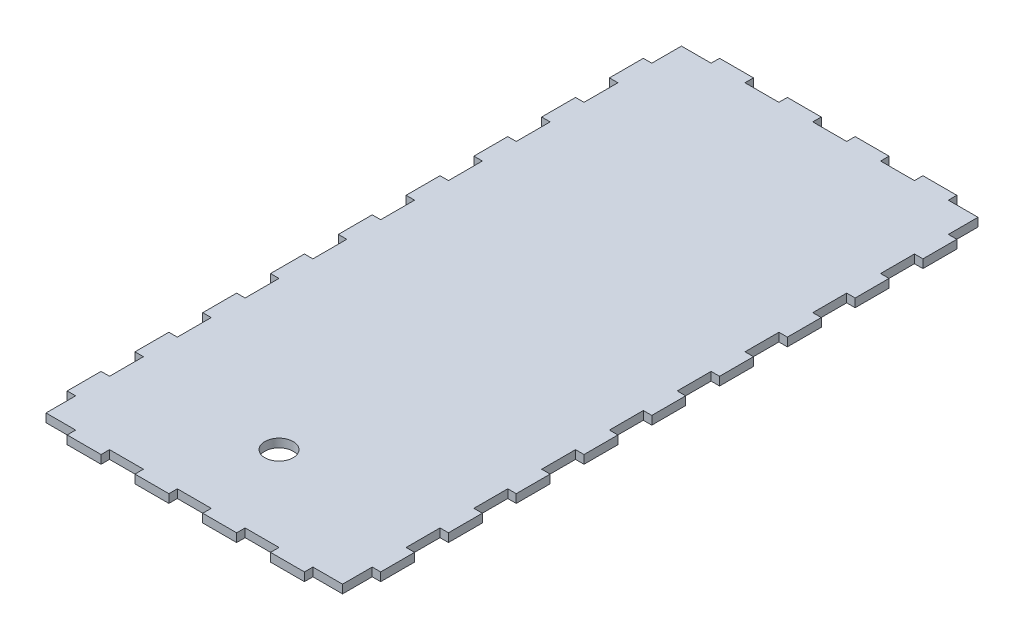
from build123d import *

# Parameters (mm, degrees)
SKETCH1_W           = 210
SKETCH1_H           = 450
SKETCH1_R           = 10
BOSS_EXTRUDE1_DEPTH = 6
SKETCH3_W           = 6
SKETCH3_H           = 24
BOSS_EXTRUDE3_DEPTH = 6
SKETCH2_W           = 24
SKETCH2_H           = 6
BOSS_EXTRUDE4_DEPTH = 6


with BuildPart() as part:
    # Sketch1 → Boss-Extrude1 (new body)
    with BuildSketch(Plane(origin=(0, 0, 0), x_dir=(1, 0, 0), z_dir=(0, 1, 0))):
        Rectangle(SKETCH1_W, SKETCH1_H)
        with Locations((0, -165)):
            Circle(SKETCH1_R, mode=Mode.SUBTRACT)
    extrude(amount=BOSS_EXTRUDE1_DEPTH)

    # Sketch3 → Boss-Extrude3 (add)
    with BuildSketch(Plane(origin=(0, 6, 0), x_dir=(1, 0, 0), z_dir=(0, 1, 0))):
        with Locations((-108, 192)):
            Rectangle(SKETCH3_W, SKETCH3_H)
        with Locations((108, 192)):
            Rectangle(SKETCH3_W, SKETCH3_H)
        with Locations((108, 144)):
            Rectangle(SKETCH3_W, SKETCH3_H)
        with Locations((108, 96)):
            Rectangle(SKETCH3_W, SKETCH3_H)
        with Locations((108, 48)):
            Rectangle(SKETCH3_W, SKETCH3_H)
        with Locations((108, 0)):
            Rectangle(SKETCH3_W, SKETCH3_H)
        with Locations((108, -48)):
            Rectangle(SKETCH3_W, SKETCH3_H)
        with Locations((108, -96)):
            Rectangle(SKETCH3_W, SKETCH3_H)
        with Locations((108, -144)):
            Rectangle(SKETCH3_W, SKETCH3_H)
        with Locations((108, -192)):
            Rectangle(SKETCH3_W, SKETCH3_H)
        with Locations((-108, 144)):
            Rectangle(SKETCH3_W, SKETCH3_H)
        with Locations((-108, 96)):
            Rectangle(SKETCH3_W, SKETCH3_H)
        with Locations((-108, 48)):
            Rectangle(SKETCH3_W, SKETCH3_H)
        with Locations((-108, 0)):
            Rectangle(SKETCH3_W, SKETCH3_H)
        with Locations((-108, -48)):
            Rectangle(SKETCH3_W, SKETCH3_H)
        with Locations((-108, -96)):
            Rectangle(SKETCH3_W, SKETCH3_H)
        with Locations((-108, -144)):
            Rectangle(SKETCH3_W, SKETCH3_H)
        with Locations((-108, -192)):
            Rectangle(SKETCH3_W, SKETCH3_H)
    extrude(amount=-BOSS_EXTRUDE3_DEPTH)

    # Sketch2 → Boss-Extrude4 (add)
    with BuildSketch(Plane(origin=(0, 6, 0), x_dir=(1, 0, 0), z_dir=(0, 1, 0))):
        with Locations((-72, 228)):
            Rectangle(SKETCH2_W, SKETCH2_H)
        with Locations((-24, 228)):
            Rectangle(SKETCH2_W, SKETCH2_H)
        with Locations((24, 228)):
            Rectangle(SKETCH2_W, SKETCH2_H)
        with Locations((72, 228)):
            Rectangle(SKETCH2_W, SKETCH2_H)
        with Locations((-72, -228)):
            Rectangle(SKETCH2_W, SKETCH2_H)
        with Locations((-24, -228)):
            Rectangle(SKETCH2_W, SKETCH2_H)
        with Locations((24, -228)):
            Rectangle(SKETCH2_W, SKETCH2_H)
        with Locations((72, -228)):
            Rectangle(SKETCH2_W, SKETCH2_H)
    extrude(amount=-BOSS_EXTRUDE4_DEPTH)


solid = part.part
